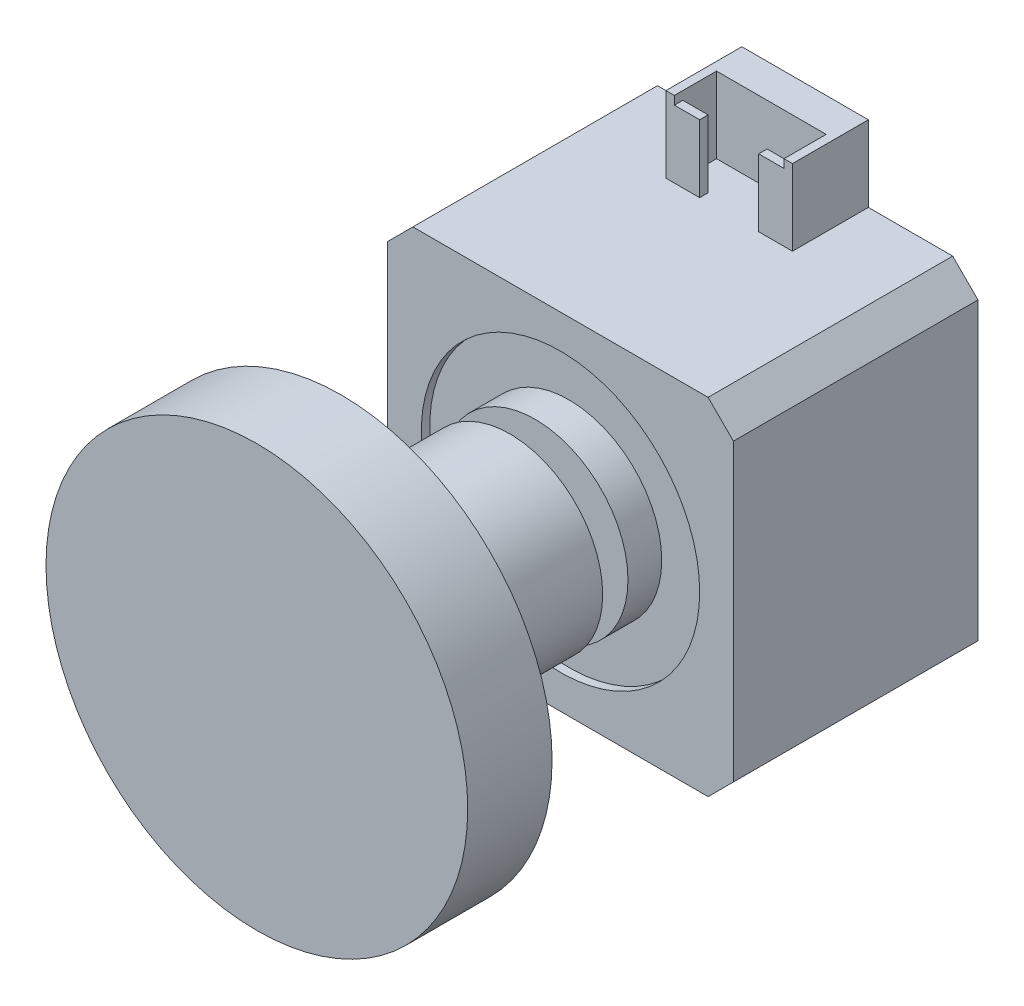
from build123d import *

# Parameters (mm, degrees)
ESQUISSE1_W             = 41
ESQUISSE1_H             = 41
BOSS_EXTRU_1_DEPTH      = 29
ESQUISSE2_R             = 16.5
ESQUISSE2_R_2           = 11
ENL_V_MAT_EXTRU_1_DEPTH = 1
BOSS_EXTRU_2_START      = 3
ESQUISSE2_3_R           = 11
ESQUISSE2_3_R_2         = 2.5
BOSS_EXTRU_2_DEPTH      = 3
BOSS_EXTRU_3_START      = 6
ESQUISSE2_4_R           = 2.5
BOSS_EXTRU_3_DEPTH      = 6
BOSS_EXTRU_4_START      = 20
ESQUISSE7_R             = 11
BOSS_EXTRU_4_DEPTH      = 20
ESQUISSE9_R             = 25
BOSS_EXTRU_5_DEPTH      = 10
CHANFREIN1_SIZE         = 3
ESQUISSE10_W            = 15
ESQUISSE10_H            = 9
ESQUISSE10_W_2          = 13
ESQUISSE10_H_2          = 4
BOSS_EXTRU_6_DEPTH      = 9
ENL_V_MAT_EXTRU_3_DEPTH = 2


with BuildPart() as part:
    # Esquisse1 → Boss.-Extru.1 (new body)
    with BuildSketch(Plane.XY):
        with Locations((20.5, 20.5)):
            Rectangle(ESQUISSE1_W, ESQUISSE1_H)
    extrude(amount=BOSS_EXTRU_1_DEPTH)

    # Esquisse2 → Enlèv. mat.-Extru.1 (cut)
    with BuildSketch(Plane.XY.offset(29)):
        with Locations((20.5, 20.5)):
            Circle(ESQUISSE2_R)
        with Locations((20.5, 20.5)):
            Circle(ESQUISSE2_R_2, mode=Mode.SUBTRACT)
    extrude(amount=-ENL_V_MAT_EXTRU_1_DEPTH, mode=Mode.SUBTRACT)

    # Esquisse2_3 → Boss.-Extru.2 (add)
    with BuildSketch(Plane.XY.offset(29).offset(BOSS_EXTRU_2_START)):
        with Locations((20.5, 20.5)):
            Circle(ESQUISSE2_3_R)
        with Locations((20.5, 20.5)):
            Circle(ESQUISSE2_3_R_2, mode=Mode.SUBTRACT)
    extrude(amount=-BOSS_EXTRU_2_DEPTH)

    # Esquisse2_4 → Boss.-Extru.3 (add)
    with BuildSketch(Plane.XY.offset(29).offset(BOSS_EXTRU_3_START)):
        with Locations((20.5, 20.5)):
            Circle(ESQUISSE2_4_R)
    extrude(amount=-BOSS_EXTRU_3_DEPTH)

    # Esquisse7 → Boss.-Extru.4 (add)
    with BuildSketch(Plane.XY.offset(35).offset(BOSS_EXTRU_4_START)):
        with Locations((20.5, 20.5)):
            Circle(ESQUISSE7_R)
    extrude(amount=-BOSS_EXTRU_4_DEPTH)

    # Esquisse9 → Boss.-Extru.5 (add)
    with BuildSketch(Plane.XY.offset(55)):
        with Locations((20.5, 20.5)):
            Circle(ESQUISSE9_R)
    extrude(amount=BOSS_EXTRU_5_DEPTH)

    # Chanfrein1
    chanfrein1_edges = [part.edges().sort_by_distance(p)[0] for p in [
        (41, 41, 14.5),
        (41, 0, 14.5),
        (0, 0, 14.5),
        (0, 41, 14.5),
    ]]
    chamfer(chanfrein1_edges, length=CHANFREIN1_SIZE)

    # Esquisse10 → Boss.-Extru.6 (add)
    with BuildSketch(Plane(origin=(0, 41, 0), x_dir=(1, 0, 0), z_dir=(0, 1, 0))):
        with Locations((20.5, -4.5)):
            Rectangle(ESQUISSE10_W, ESQUISSE10_H)
        with Locations((20.5, -6)):
            Rectangle(ESQUISSE10_W_2, ESQUISSE10_H_2, mode=Mode.SUBTRACT)
    extrude(amount=BOSS_EXTRU_6_DEPTH)

    # Esquisse11 → Enlèv. mat.-Extru.3 (cut)
    with BuildSketch(Plane.XY.offset(9)):
        Polygon((17, 41), (24, 41), (24, 49), (27, 49), (27, 50), (14, 50), (14, 49), (17, 49), align=None)
    extrude(amount=-ENL_V_MAT_EXTRU_3_DEPTH, mode=Mode.SUBTRACT)


solid = part.part
